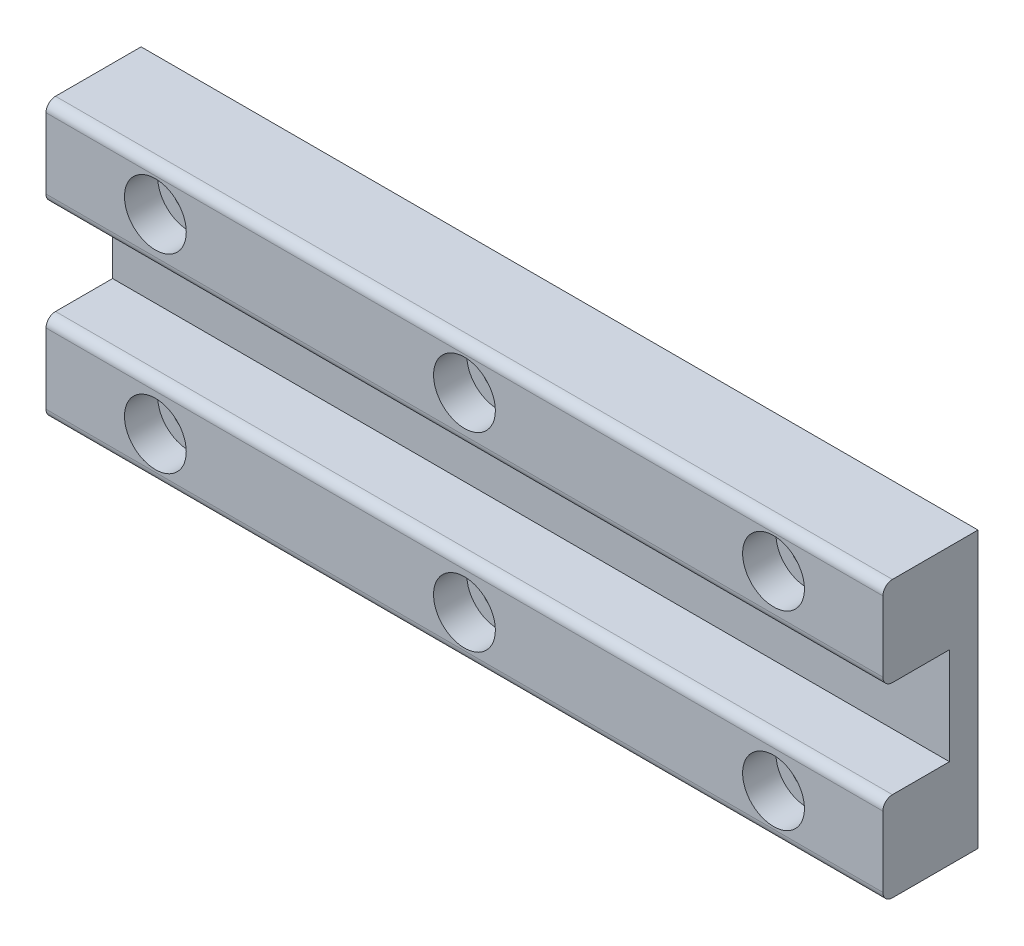
from build123d import *

# Parameters (mm, degrees)
SKETCH_1_W          = 255
SKETCH_1_H          = 80
EXTRUDE_1_DEPTH     = 5
SKETCH_2_R          = 5
CUT_EXTRUDE_1_DEPTH = 5
SKETCH_3_R          = 4
CUT_EXTRUDE_2_DEPTH = 10
SKETCH_4_W          = 88
SKETCH_4_H          = 20
EXTRUDE_2_DEPTH     = 10
SKETCH_5_R          = 15
CUT_EXTRUDE_3_DEPTH = 10
SKETCH_6_R          = 7
EXTRUDE_3_DEPTH     = 15
HOLE_WIZARD_M6_1_D  = 5
CUT_EXTRUDE_4_DEPTH = 7
HOLE_WIZARD_M4_1_D  = 3.3
FILLET_1_R          = 10
SKETCH_13_R         = 6.969385005
EXTRUDE_5_DEPTH     = 5
SKETCH_14_W         = 5
SKETCH_14_H         = 75
EXTRUDE_6_DEPTH     = 80
SKETCH_15_W         = 20
SKETCH_15_H         = 5
EXTRUDE_7_DEPTH     = 80
EXTRUDE_8_DEPTH     = 5
SKETCH_17_R         = 3
CUT_EXTRUDE_5_DEPTH = 5
FILLET_2_R          = 1
SKETCH_18_W         = 309.613912266
SKETCH_18_H         = 134.290371586
CUT_EXTRUDE_6_DEPTH = 81
SKETCH_19_R         = 17
CUT_EXTRUDE_7_DEPTH = 11
SKETCH_20_W         = 10
SKETCH_20_H         = 4.5
EXTRUDE_9_DEPTH     = 88
SKETCH_21_R         = 1.75
CUT_EXTRUDE_8_DEPTH = 11
SKETCH_22_R         = 3.25
CUT_EXTRUDE_9_DEPTH = 3.5
FILLET_4_R          = 1


with BuildPart() as part:
    # 草图1 → 凸台-拉伸1 (new body)
    with BuildSketch(Plane.XY):
        Rectangle(SKETCH_1_W, SKETCH_1_H)
    extrude(amount=EXTRUDE_1_DEPTH)

    # 草图2 → 切除-拉伸1 (cut)
    with BuildSketch(Plane.XY.offset(5)):
        with Locations((-107.5, 0)):
            Circle(SKETCH_2_R)
    extrude(amount=-CUT_EXTRUDE_1_DEPTH, mode=Mode.SUBTRACT)

    # 草图3 → 切除-拉伸2 (cut)
    with BuildSketch(Plane.XY.offset(5)):
        with Locations((-45, 0)):
            Circle(SKETCH_3_R)
    extrude(amount=-CUT_EXTRUDE_2_DEPTH, mode=Mode.SUBTRACT)

    # 草图4 → 凸台-拉伸2 (add)
    with BuildSketch(Plane.XY.offset(5)):
        with Locations((-9.5, 0)):
            Rectangle(SKETCH_4_W, SKETCH_4_H)
    extrude(amount=EXTRUDE_2_DEPTH)

    # 草图5 → 切除-拉伸3 (cut)
    with BuildSketch(Plane.XY.offset(5)):
        with Locations((70, 0)):
            Circle(SKETCH_5_R)
    extrude(amount=-CUT_EXTRUDE_3_DEPTH, mode=Mode.SUBTRACT)

    # 草图6 → 凸台-拉伸3 (add)
    with BuildSketch(Plane(origin=(0, 0, 0), x_dir=(-1, 0, 0), z_dir=(0, 0, -1))):
        with Locations((107.5, 0)):
            Circle(SKETCH_6_R)
    extrude(amount=-EXTRUDE_3_DEPTH)

    # M6 螺纹孔1 (through all)
    with Locations(Plane.XY.offset(15)):
        with Locations((-107.5, 0)):
            Hole(HOLE_WIZARD_M6_1_D / 2)

    # 草图10 → 切除-拉伸4 (cut)
    with BuildSketch(Plane.XY.offset(15)):
        with BuildLine():
            Line((-53.5, 5.1), (34.5, 5.1))
            ThreePointArc((34.5, 5.1), (39.6, 0), (34.5, -5.1))
            Line((34.5, -5.1), (-53.5, -5.1))
            ThreePointArc((-53.5, -5.1), (-58.6, 0), (-53.5, 5.1))
        make_face()
    extrude(amount=-CUT_EXTRUDE_4_DEPTH, mode=Mode.SUBTRACT)

    # M4 螺纹孔1 (through all)
    with Locations(Plane(origin=(0, 0, 0), x_dir=(-1, 0, 0), z_dir=(0, 0, -1))):
        with Locations((-39.75, -26.5), (-39.75, -1.5), (-109.94007449, -26.5), (-100.25, -1.5)):
            Hole(HOLE_WIZARD_M4_1_D / 2)

    # 圆角1
    fillet_1_edges = [part.edges().sort_by_distance(p)[0] for p in [
        (-127.5, 40, 2.5),
        (-127.5, -40, 2.5),
    ]]
    fillet(fillet_1_edges, radius=FILLET_1_R)

    # 草图13 → 凸台-拉伸5 (add)
    with BuildSketch(Plane.XY.offset(5)):
        with Locations((-45, 0)):
            Circle(SKETCH_13_R)
    extrude(amount=-EXTRUDE_5_DEPTH)

    # 草图14 → 凸台-拉伸6 (add)
    with BuildSketch(Plane.XZ.offset(40)):
        with Locations((125, -37.5)):
            Rectangle(SKETCH_14_W, SKETCH_14_H)
    extrude(amount=-EXTRUDE_6_DEPTH)

    # 草图15 → 凸台-拉伸7 (add)
    with BuildSketch(Plane.XZ.offset(40)):
        with Locations((112.5, -72.5)):
            Rectangle(SKETCH_15_W, SKETCH_15_H)
    extrude(amount=-EXTRUDE_7_DEPTH)

    # 草图16 → 凸台-拉伸8 (add)
    with BuildSketch(Plane.XZ.offset(40)):
        Polygon((-32.5, 5), (-32.5, 0), (102.5, -75), (127.5, -75), (127.5, 5), align=None)
    extrude_8 = extrude(amount=-EXTRUDE_8_DEPTH)

    # 镜向1: 凸台-拉伸8 across plane
    add(extrude_8.mirror(Plane.ZX))

    # 草图17 → 切除-拉伸5 (cut)
    with BuildSketch(Plane(origin=(0, 0, -75), x_dir=(-1, 0, 0), z_dir=(0, 0, -1))):
        with Locations((-114.5, -15)):
            Circle(SKETCH_17_R)
        with Locations((-114.5, 15)):
            Circle(SKETCH_17_R)
    extrude(amount=-CUT_EXTRUDE_5_DEPTH, mode=Mode.SUBTRACT)

    # 圆角2
    fillet_2_edges = [part.edges().sort_by_distance(p)[0] for p in [
        (-127.5, 0, 0),
        (-124.571067812, 37.071067812, 0),
        (-124.571067812, -37.071067812, 0),
        (-127.5, 0, 5),
        (-124.571067812, 37.071067812, 5),
        (-124.571067812, -37.071067812, 5),
        (127.5, 0, -75),
        (115, -40, -75),
        (115, 40, -75),
        (127.5, 0, 5),
        (35, -40, -37.5),
        (35, -35, -37.5),
        (5, 40, 5),
        (-75, 40, 0),
        (35, 40, -37.5),
        (35, 35, -37.5),
        (127.5, 40, -35),
        (127.5, -40, -35),
        (-75, -40, 0),
        (5, -40, 5),
    ]]
    fillet(fillet_2_edges, radius=FILLET_2_R)

    # 草图18 → 切除-拉伸6 (cut, through all)
    with BuildSketch(Plane.XY.offset(5)):
        Rectangle(SKETCH_18_W, SKETCH_18_H)
    extrude(amount=-CUT_EXTRUDE_6_DEPTH, mode=Mode.SUBTRACT)

    # 草图19 → 切除-拉伸7 (cut, through all)
    with BuildSketch(Plane.XY.offset(15)):
        with Locations((-107.5, 0)):
            Circle(SKETCH_19_R)
    extrude(amount=-CUT_EXTRUDE_7_DEPTH, mode=Mode.SUBTRACT)

    # 草图20 → 凸台-拉伸9 (add)
    with BuildSketch(Plane(origin=(34.5, 0, 0), x_dir=(0, 0, -1), z_dir=(1, 0, 0))):
        with Locations((-10, 12.25)):
            Rectangle(SKETCH_20_W, SKETCH_20_H)
    extrude_9 = extrude(amount=-EXTRUDE_9_DEPTH)

    # 镜向2: 凸台-拉伸9 across plane
    add(extrude_9.mirror(Plane.ZX))

    # 草图21 → 切除-拉伸8 (cut, through all)
    with BuildSketch(Plane.XY.offset(15)):
        with Locations((-42, 10)):
            Circle(SKETCH_21_R)
        with Locations((-9.5, 10)):
            Circle(SKETCH_21_R)
        with Locations((23, 10)):
            Circle(SKETCH_21_R)
        with Locations((23, -10)):
            Circle(SKETCH_21_R)
        with Locations((-9.5, -10)):
            Circle(SKETCH_21_R)
        with Locations((-42, -10)):
            Circle(SKETCH_21_R)
    extrude(amount=-CUT_EXTRUDE_8_DEPTH, mode=Mode.SUBTRACT)

    # 草图22 → 切除-拉伸9 (cut)
    with BuildSketch(Plane.XY.offset(15)):
        with Locations((-42, 10)):
            Circle(SKETCH_22_R)
        with Locations((-9.5, 10)):
            Circle(SKETCH_22_R)
        with Locations((23, 10)):
            Circle(SKETCH_22_R)
        with Locations((23, -10)):
            Circle(SKETCH_22_R)
        with Locations((-9.5, -10)):
            Circle(SKETCH_22_R)
        with Locations((-42, -10)):
            Circle(SKETCH_22_R)
    extrude(amount=-CUT_EXTRUDE_9_DEPTH, mode=Mode.SUBTRACT)

    # 圆角4
    fillet_4_edges = [part.edges().sort_by_distance(p)[0] for p in [
        (-9.5, 14.5, 15),
        (-9.5, -14.5, 15),
        (-9.5, 5.1, 15),
        (-9.5, -5.1, 15),
    ]]
    fillet(fillet_4_edges, radius=FILLET_4_R)


solid = part.part
